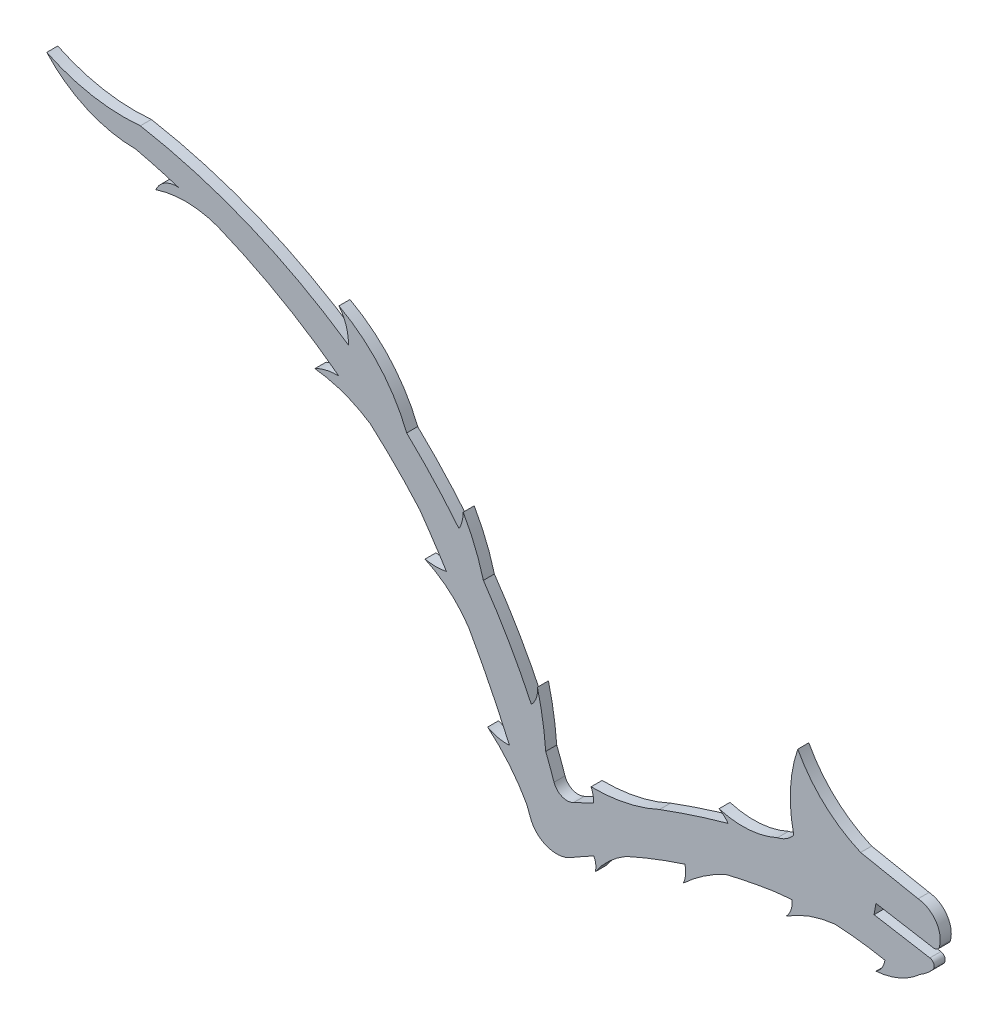
from build123d import *

# Parameters (mm, degrees)
BOSS_EXTRUDE1_DEPTH = 1.524


with BuildPart() as part:
    # Sketch1 → Boss-Extrude1 (new body)
    with BuildSketch(Plane.XY):
        with BuildLine():
            Line((47.381308576, -13.076354562), (55.343944742, -14.432422978))
            ThreePointArc((55.343944742, -14.432422978), (55.855819335, -14.328185498), (56.163893215, -13.906318771))
            ThreePointArc((56.163893215, -13.906318771), (55.680504041, -11.077688455), (53.220198686, -9.600626466))
            Line((53.220198686, -9.600626466), (45.266067061, -8.034115775))
            ThreePointArc((45.266067061, -8.034115775), (40.237375781, -4.755718158), (36.574211612, 0))
            ThreePointArc((36.574211612, 0), (35.55871494, -5.254533576), (36.018806888, -10.586481811))
            ThreePointArc((36.018806888, -10.586481811), (35.025995436, -11.496620285), (33.780750037, -12.009836144))
            ThreePointArc((33.780750037, -12.009836144), (29.778374213, -13.039276401), (25.669954537, -12.592457382))
            ThreePointArc((25.669954537, -12.592457382), (26.366552456, -13.076757004), (26.920206789, -13.719611314))
            ThreePointArc((26.920206789, -13.719611314), (22.157152762, -15.15851527), (17.456411215, -16.789514096))
            ThreePointArc((17.456411215, -16.789514096), (12.832168531, -18.332197491), (7.980688074, -18.808254041))
            ThreePointArc((7.980688074, -18.808254041), (8.253415585, -19.676221582), (8.349810899, -20.580907104))
            ThreePointArc((8.349810899, -20.580907104), (6.937406163, -21.247776917), (5.53361242, -21.932587557))
            ThreePointArc((5.53361242, -21.932587557), (3.944680946, -21.988663657), (2.853783543, -20.83203467))
            ThreePointArc((2.853783543, -20.83203467), (2.29585657, -19.263543096), (1.704966772, -17.707169885))
            ThreePointArc((1.704966772, -17.707169885), (1.284069131, -14.122482995), (0.560307739, -10.586481811))
            ThreePointArc((0.560307739, -10.586481811), (0.415674848, -11.924982959), (-0.282069682, -13.076354562))
            ThreePointArc((-0.282069682, -13.076354562), (-3.357054523, -7.162746337), (-6.920105474, -1.52972211))
            ThreePointArc((-6.920105474, -1.52972211), (-8.0910802, 1.949544484), (-9.710699696, 5.243980782))
            ThreePointArc((-9.710699696, 5.243980782), (-9.857305852, 4.075018277), (-10.290972629, 2.979618885))
            ThreePointArc((-10.290972629, 2.979618885), (-13.777130717, 7.023766683), (-17.528779794, 10.822919067))
            ThreePointArc((-17.528779794, 10.822919067), (-21.284368064, 16.919530678), (-26.897153204, 21.365850433))
            ThreePointArc((-26.897153204, 21.365850433), (-25.887369361, 19.461878078), (-25.598425379, 17.326161451))
            ThreePointArc((-25.598425379, 17.326161451), (-39.347249709, 24.806966458), (-54.370546376, 29.199365714))
            ThreePointArc((-54.370546376, 29.199365714), (-61.003451809, 29.476578966), (-67.319072822, 31.522358252))
            ThreePointArc((-67.319072822, 31.522358252), (-61.733688319, 27.51480849), (-55.009920851, 26.08375078))
            ThreePointArc((-55.009920851, 26.08375078), (-52.038783927, 25.331807522), (-49.101103933, 24.458246116))
            ThreePointArc((-49.101103933, 24.458246116), (-50.963404132, 24.042209603), (-52.230913262, 22.615791355))
            ThreePointArc((-52.230913262, 22.615791355), (-47.957226248, 23.275149282), (-43.703205331, 22.498966559))
            ThreePointArc((-43.703205331, 22.498966559), (-34.98884104, 18.269729883), (-26.897153204, 12.945147661))
            ThreePointArc((-26.897153204, 12.945147661), (-28.611374467, 12.792404738), (-30.222607976, 12.187581193))
            ThreePointArc((-30.222607976, 12.187581193), (-26.225509878, 11.251375507), (-22.559534857, 9.403700904))
            ThreePointArc((-22.559534857, 9.403700904), (-19.030321473, 6.083870505), (-15.72447016, 2.541559382))
            ThreePointArc((-15.72447016, 2.541559382), (-13.836348231, -0.215104475), (-12.02203426, -3.020895781))
            ThreePointArc((-12.02203426, -3.020895781), (-13.508524403, -3.175087526), (-14.995014547, -3.020895781))
            ThreePointArc((-14.995014547, -3.020895781), (-11.58739515, -5.203150516), (-8.916043995, -8.242556493))
            ThreePointArc((-8.916043995, -8.242556493), (-5.974041698, -13.791075709), (-3.312350182, -19.479383127))
            ThreePointArc((-3.312350182, -19.479383127), (-4.870972445, -19.369578502), (-6.329147764, -18.808254041))
            ThreePointArc((-6.329147764, -18.808254041), (-3.312350182, -21.839623943), (-0.906453557, -25.375431145))
            ThreePointArc((-0.906453557, -25.375431145), (-0.657734758, -26.037552601), (-0.412739096, -26.701060692))
            ThreePointArc((-0.412739096, -26.701060692), (1.91016195, -29.006645717), (5.168319653, -28.696807117))
            ThreePointArc((5.168319653, -28.696807117), (6.748763707, -27.788827847), (8.349810899, -26.917692008))
            ThreePointArc((8.349810899, -26.917692008), (8.630214839, -27.78643645), (8.562623992, -28.696807117))
            ThreePointArc((8.562623992, -28.696807117), (10.486664845, -26.455513742), (12.868412887, -24.70834304))
            ThreePointArc((12.868412887, -24.70834304), (16.869160672, -23.03916113), (20.955745156, -21.592793838))
            ThreePointArc((20.955745156, -21.592793838), (21.05258172, -22.797241034), (20.746541516, -23.966176344))
            ThreePointArc((20.746541516, -23.966176344), (23.495531579, -21.764324116), (26.549791209, -20.010300822))
            ThreePointArc((26.549791209, -20.010300822), (29.81474898, -19.288764723), (33.107408372, -18.706563972))
            ThreePointArc((33.107408372, -18.706563972), (34.43330114, -18.558524355), (35.762761976, -18.446984027))
            ThreePointArc((35.762761976, -18.446984027), (35.632573955, -19.733193435), (34.951522192, -20.83203467))
            ThreePointArc((34.951522192, -20.83203467), (38.192011454, -19.210457415), (41.722919829, -18.396228022))
            ThreePointArc((41.722919829, -18.396228022), (45.188062045, -18.704651863), (48.622209673, -19.26049889))
            ThreePointArc((48.622209673, -19.26049889), (48.214896908, -20.366352247), (47.381308576, -21.199386357))
            ThreePointArc((47.381308576, -21.199386357), (50.647879824, -20.381891812), (53.469866719, -18.544726873))
            ThreePointArc((53.469866719, -18.544726873), (54.428390669, -17.883217687), (55.261101332, -17.068996882))
            ThreePointArc((55.261101332, -17.068996882), (55.403709497, -16.34876081), (54.842730354, -15.875073687))
            Line((54.842730354, -15.875073687), (47.128232405, -14.561068095))
            Line((47.128232405, -14.561068095), (47.381308576, -13.076354562))
        make_face()
    extrude(amount=BOSS_EXTRUDE1_DEPTH)


solid = part.part
